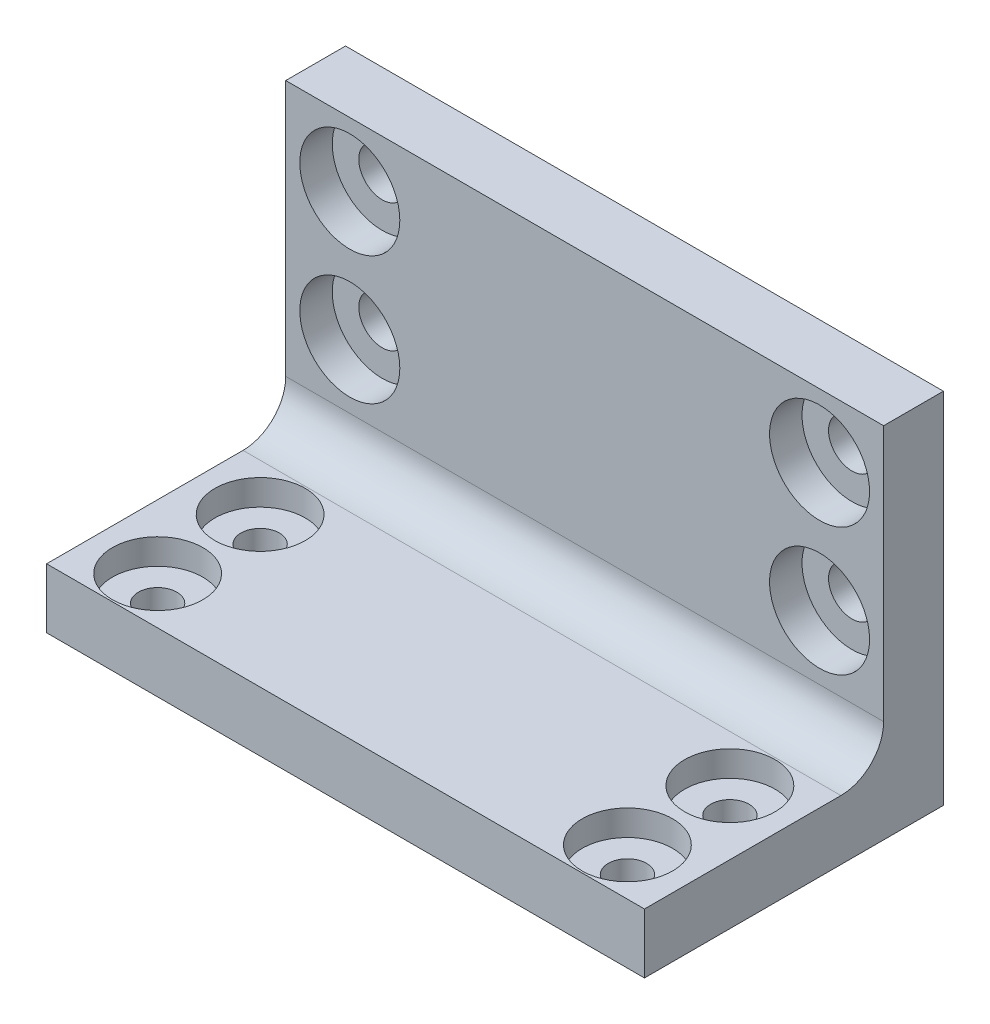
from build123d import *

# Parameters (mm, degrees)
SKETCH1_W                                        = 70
SKETCH1_H                                        = 35
BOSS_EXTRUDE1_DEPTH                              = 7
SKETCH2_W                                        = 70
SKETCH2_H                                        = 7
BOSS_EXTRUDE2_DEPTH                              = 35
FILLET1_R                                        = 5
CBORE_FOR_M5_HEX_HEAD_MACHINE_SCREW1_D           = 5.5
CBORE_FOR_M5_HEX_HEAD_MACHINE_SCREW1_CBORE_D     = 11.71
CBORE_FOR_M5_HEX_HEAD_MACHINE_SCREW1_CBORE_DEPTH = 3.8
CBORE_FOR_M4_HEX_HEAD_MACHINE_SCREW2_D           = 4.5
CBORE_FOR_M4_HEX_HEAD_MACHINE_SCREW2_CBORE_D     = 10.59
CBORE_FOR_M4_HEX_HEAD_MACHINE_SCREW2_CBORE_DEPTH = 3


with BuildPart() as part:
    # Sketch1 → Boss-Extrude1 (new body)
    with BuildSketch(Plane(origin=(0, 0, 0), x_dir=(1, 0, 0), z_dir=(0, 1, 0))):
        with Locations((0, -17.5)):
            Rectangle(SKETCH1_W, SKETCH1_H)
    extrude(amount=BOSS_EXTRUDE1_DEPTH)

    # Sketch2 → Boss-Extrude2 (add)
    with BuildSketch(Plane(origin=(0, 7, 0), x_dir=(1, 0, 0), z_dir=(0, 1, 0))):
        with Locations((0, -3.5)):
            Rectangle(SKETCH2_W, SKETCH2_H)
    extrude(amount=BOSS_EXTRUDE2_DEPTH)

    # Fillet1
    fillet1_edges = [part.edges().sort_by_distance(p)[0] for p in [
        (0, 7, 7),
    ]]
    fillet(fillet1_edges, radius=FILLET1_R)

    # CBORE for M5 Hex Head Machine Screw1 (through all)
    with Locations(Plane.XY.offset(7)):
        with Locations((-27.5, 34.5), (27.5, 34.5), (27.5, 19.5), (-27.5, 19.5)):
            CounterBoreHole(CBORE_FOR_M5_HEX_HEAD_MACHINE_SCREW1_D / 2, CBORE_FOR_M5_HEX_HEAD_MACHINE_SCREW1_CBORE_D / 2, CBORE_FOR_M5_HEX_HEAD_MACHINE_SCREW1_CBORE_DEPTH)

    # CBORE for M4 Hex Head Machine Screw2 (through all)
    with Locations(Plane(origin=(0, 7, 0), x_dir=(1, 0, 0), z_dir=(0, 1, 0))):
        with Locations((-27.5, -17.5), (-27.5, -29.5), (27.5, -17.5), (27.5, -29.5)):
            CounterBoreHole(CBORE_FOR_M4_HEX_HEAD_MACHINE_SCREW2_D / 2, CBORE_FOR_M4_HEX_HEAD_MACHINE_SCREW2_CBORE_D / 2, CBORE_FOR_M4_HEX_HEAD_MACHINE_SCREW2_CBORE_DEPTH)


solid = part.part
